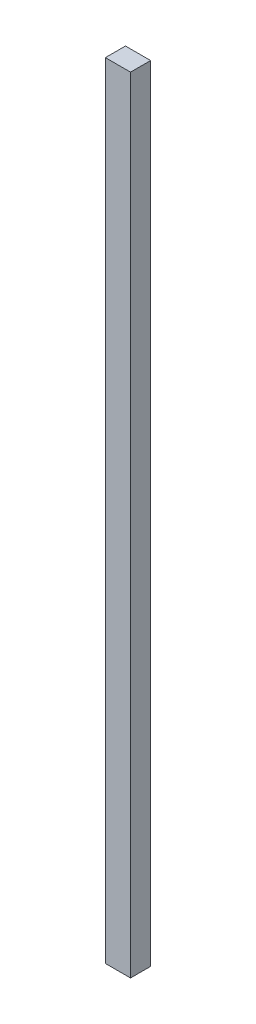
from build123d import *

# Parameters (mm, degrees)
SKETCH_1_W      = 25
SKETCH_1_H      = 20
EXTRUDE_1_DEPTH = 780


with BuildPart() as part:
    # Эскиз1 → Бобышка-Вытянуть1 (new body)
    with BuildSketch(Plane(origin=(0, 0, 0), x_dir=(1, 0, 0), z_dir=(0, 1, 0))):
        with Locations((12.5, 10)):
            Rectangle(SKETCH_1_W, SKETCH_1_H)
    extrude(amount=EXTRUDE_1_DEPTH)


solid = part.part
